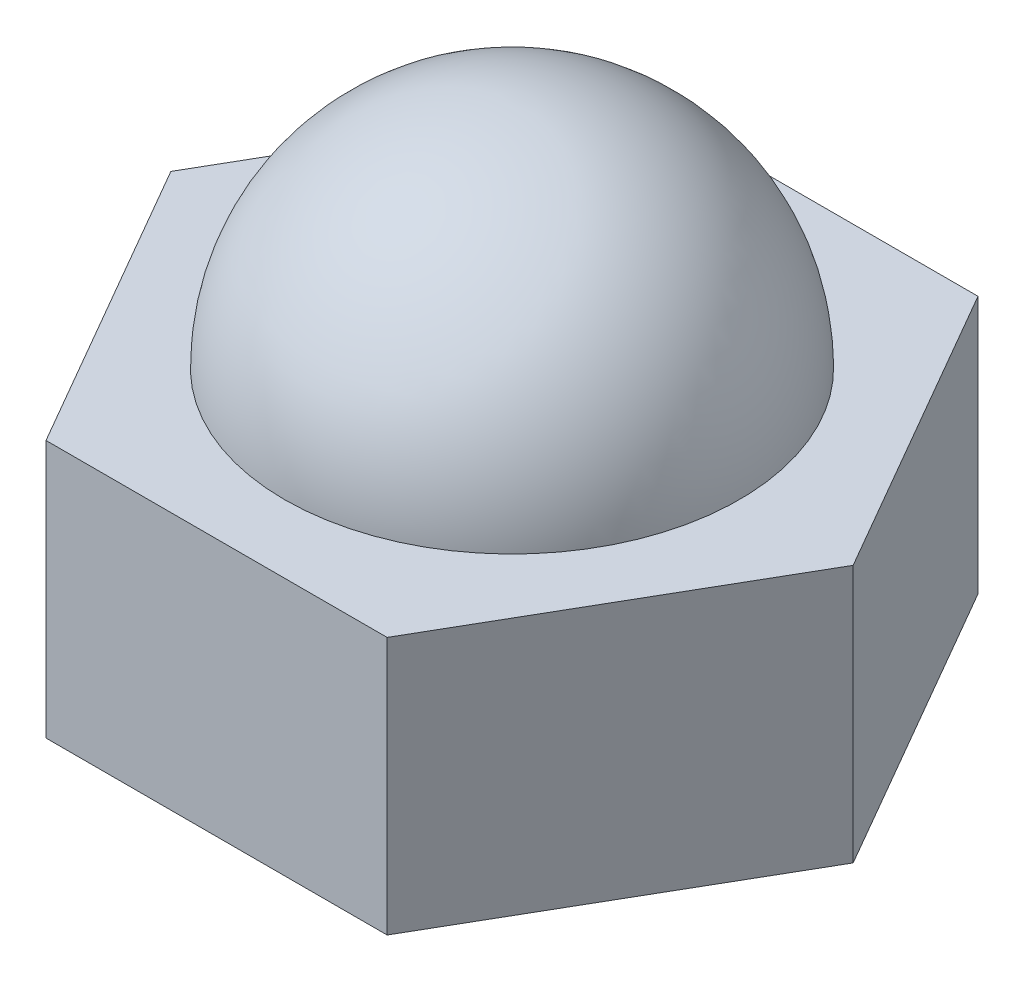
from build123d import *

# Parameters (mm, degrees)
BOSS_EXTRUDE1_DEPTH = 3.4
SKETCH4_R           = 2.5
CUT_EXTRUDE1_DEPTH  = 1.2


with BuildPart() as part:
    # Sketch1 → Boss-Extrude1 (new body)
    with BuildSketch(Plane(origin=(0, 0, 0), x_dir=(1, 0, 0), z_dir=(0, 1, 0))):
        Polygon((2.25, 3.897114317), (-2.25, 3.897114317), (-4.5, 0), (-2.25, -3.897114317), (2.25, -3.897114317), (4.5, 0), align=None)
    extrude(amount=BOSS_EXTRUDE1_DEPTH)

    # Sketch2 → Revolve1 (revolve)
    with BuildSketch(Plane(origin=(0, 3.4, 0), x_dir=(1, 0, 0), z_dir=(0, 1, 0))):
        with BuildLine():
            Line((0, 3), (0, -3))
            ThreePointArc((0, -3), (3, 0), (0, 3))
        make_face()
    revolve(axis=Axis((0, 3.4, -3), (0, 0, 1)))

    # Sketch4 → Cut-Extrude1 (cut)
    with BuildSketch(Plane.XZ):
        Circle(SKETCH4_R)
    extrude(amount=-CUT_EXTRUDE1_DEPTH, mode=Mode.SUBTRACT)


solid = part.part
